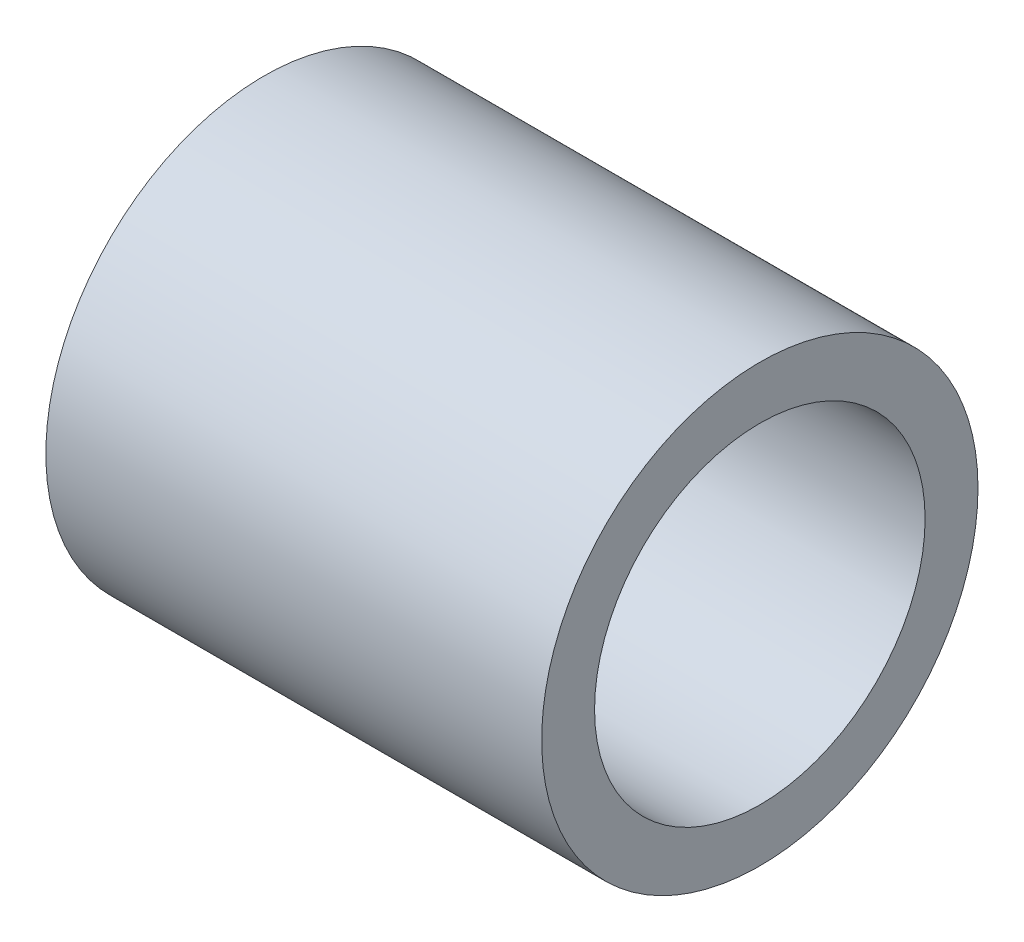
from build123d import *

# Parameters (mm, degrees)
SKETCH1_R           = 4.191
SKETCH1_R_2         = 3.175
BOSS_EXTRUDE1_DEPTH = 9.525


with BuildPart() as part:
    # Sketch1 → Boss-Extrude1 (new body)
    with BuildSketch(Plane(origin=(0, 0, 0), x_dir=(0, 0, -1), z_dir=(1, 0, 0))):
        Circle(SKETCH1_R)
        Circle(SKETCH1_R_2, mode=Mode.SUBTRACT)
    extrude(amount=BOSS_EXTRUDE1_DEPTH)


solid = part.part
